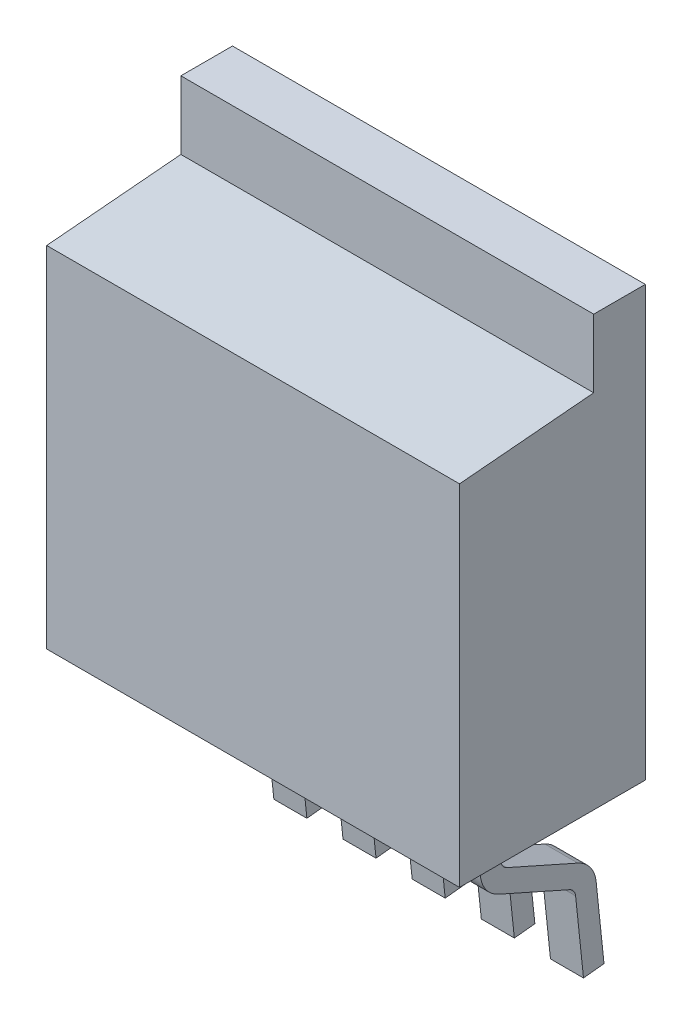
from build123d import *

# Parameters (mm, degrees)
SKETCH1_W           = 10.16
SKETCH1_H           = 10.5664
BOSS_EXTRUDE1_DEPTH = 1.27
SKETCH2_W           = 10.16
SKETCH2_H           = 8.89
BOSS_EXTRUDE2_DEPTH = 3.302
DRAFT1_ANGLE        = 5
EXTRUDE_THIN1_DEPTH = 0.4064
LPATTERN1_COUNT     = 5
LPATTERN1_PITCH     = 1.7018


with BuildPart() as part:
    # Sketch1 → Boss-Extrude1 (new body)
    with BuildSketch(Plane.XY):
        with Locations((5.08, 5.2832)):
            Rectangle(SKETCH1_W, SKETCH1_H)
    extrude(amount=BOSS_EXTRUDE1_DEPTH)

    # Sketch2 → Boss-Extrude2 (add)
    with BuildSketch(Plane.XY.offset(1.27)):
        with Locations((5.08, 4.445)):
            Rectangle(SKETCH2_W, SKETCH2_H)
    extrude(amount=BOSS_EXTRUDE2_DEPTH)

    # Draft1
    draft1_faces = [part.faces().sort_by_distance(p)[0] for p in [
        (5.08, 8.89, 2.921),
    ]]
    draft(draft1_faces, Plane.XY.offset(1.27), DRAFT1_ANGLE)

    # Sketch3 → Extrude-Thin1 (add, symmetric)
    with BuildSketch(Plane.ZY.offset(-1.6764)):
        with BuildLine():
            Line((2.286, 0), (2.286, -1.199738518))
            ThreePointArc((2.286, -1.199738518), (2.244995599, -1.338117976), (2.13522146, -1.431818957))
            Line((2.13522146, -1.431818957), (0.388422724, -2.208735427))
            ThreePointArc((0.388422724, -2.208735427), (0.081702678, -2.456965316), (-0.05973858, -2.825326055))
            Line((-0.05973858, -2.825326055), (-0.254, -4.6736))
            Line((-0.254, -4.6736), (0.251217123, -4.726700459))
            Line((0.251217123, -4.726700459), (0.445478542, -2.878426515))
            ThreePointArc((0.445478542, -2.878426515), (0.492625629, -2.755639602), (0.594865644, -2.672896305))
            Line((0.594865644, -2.672896305), (2.34166438, -1.895979835))
            ThreePointArc((2.34166438, -1.895979835), (2.670986798, -1.614876894), (2.794, -1.199738518))
            Line((2.794, -1.199738518), (2.794, 0))
            Line((2.794, 0), (2.286, 0))
        make_face()
    extrude_thin1 = extrude(amount=EXTRUDE_THIN1_DEPTH, both=True)

    # LPattern1: Extrude-Thin1 ×5
    with Locations(*[(i * LPATTERN1_PITCH, 0, 0) for i in range(1, LPATTERN1_COUNT)]):
        add(extrude_thin1)


solid = part.part
